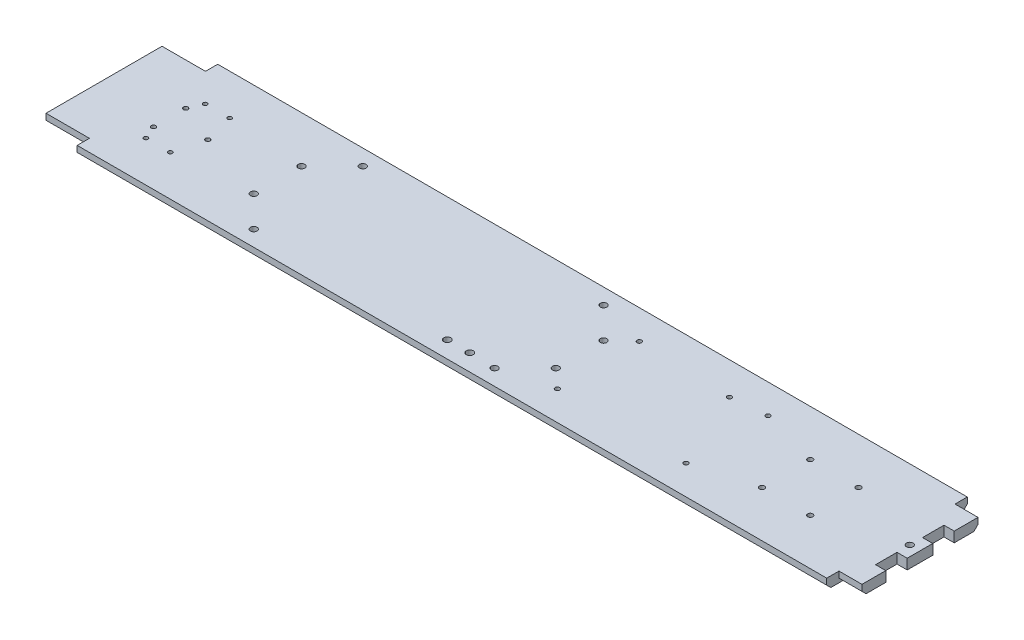
from build123d import *

# Parameters (mm, degrees)
SKETCH1_W           = 520
SKETCH1_H           = 87.376
BOSS_EXTRUDE1_DEPTH = 6.35
SKETCH3_W           = 27
SKETCH3_H           = 7.62
CUT_EXTRUDE2_DEPTH  = 7.35
SKETCH6_W           = 12.7
SKETCH6_H           = 72.136
CUT_EXTRUDE5_DEPTH  = 7.35
SKETCH8_R           = 1.4
CUT_EXTRUDE7_DEPTH  = 7.35
SKETCH9_R           = 2.05
CUT_EXTRUDE8_DEPTH  = 7.35
CHAMFER1_SIZE       = 2.54
SKETCH10_R          = 1.4
CUT_EXTRUDE9_DEPTH  = 7.35
SKETCH11_R          = 2.05
CUT_EXTRUDE10_DEPTH = 7.35
SKETCH12_R          = 1.27
CUT_EXTRUDE11_DEPTH = 7.35
SKETCH13_W          = 6.35
SKETCH13_H          = 13.335
CUT_EXTRUDE12_DEPTH = 7.35
SKETCH14_R          = 1.6
CUT_EXTRUDE13_DEPTH = 7.35
SKETCH15_R          = 2.15
CUT_EXTRUDE14_DEPTH = 7.35


with BuildPart() as part:
    # Sketch1 → Boss-Extrude1 (new body)
    with BuildSketch(Plane(origin=(0, 0, 0), x_dir=(1, 0, 0), z_dir=(0, 1, 0))):
        Rectangle(SKETCH1_W, SKETCH1_H)
    extrude(amount=BOSS_EXTRUDE1_DEPTH)

    # Sketch3 → Cut-Extrude2 (cut, through all)
    with BuildSketch(Plane(origin=(0, 6.35, 0), x_dir=(1, 0, 0), z_dir=(0, 1, 0))):
        with Locations((-246.5, 39.878)):
            Rectangle(SKETCH3_W, SKETCH3_H)
        with Locations((-246.5, -39.878)):
            Rectangle(SKETCH3_W, SKETCH3_H)
        with Locations((246.5, -39.878)):
            Rectangle(SKETCH3_W, SKETCH3_H)
        with Locations((246.5, 39.878)):
            Rectangle(SKETCH3_W, SKETCH3_H)
    extrude(amount=-CUT_EXTRUDE2_DEPTH, mode=Mode.SUBTRACT)

    # Sketch6 → Cut-Extrude5 (cut, through all)
    with BuildSketch(Plane(origin=(0, 6.35, 0), x_dir=(1, 0, 0), z_dir=(0, 1, 0))):
        with Locations((253.65, 0)):
            Rectangle(SKETCH6_W, SKETCH6_H)
    extrude(amount=-CUT_EXTRUDE5_DEPTH, mode=Mode.SUBTRACT)

    # Sketch8 → Cut-Extrude7 (cut, through all)
    with BuildSketch(Plane(origin=(0, 6.35, 0), x_dir=(1, 0, 0), z_dir=(0, 1, 0))):
        with Locations((-219.2, 10)):
            Circle(SKETCH8_R)
        with Locations((-219.2, -10)):
            Circle(SKETCH8_R)
        with Locations((-195.5, 0)):
            Circle(SKETCH8_R)
    extrude(amount=-CUT_EXTRUDE7_DEPTH, mode=Mode.SUBTRACT)

    # Sketch9 → Cut-Extrude8 (cut, through all)
    with BuildSketch(Plane(origin=(0, 6.35, 0), x_dir=(1, 0, 0), z_dir=(0, 1, 0))):
        with Locations((-133, 33.89)):
            Circle(SKETCH9_R)
        with Locations((-152.05, 14.84)):
            Circle(SKETCH9_R)
        with Locations((-152.05, -14.84)):
            Circle(SKETCH9_R)
        with Locations((-133, -33.89)):
            Circle(SKETCH9_R)
        with Locations((16.68, 33.89)):
            Circle(SKETCH9_R)
        with Locations((35.73, 14.84)):
            Circle(SKETCH9_R)
        with Locations((35.73, -14.84)):
            Circle(SKETCH9_R)
        with Locations((16.68, -33.89)):
            Circle(SKETCH9_R)
    extrude(amount=-CUT_EXTRUDE8_DEPTH, mode=Mode.SUBTRACT)

    # Chamfer1
    chamfer1_edges = [part.edges().sort_by_distance(p)[0] for p in [
        (0, 0, -43.688),
        (0, 0, 43.688),
        (240.15, 0, -36.068),
        (-246.5, 0, 36.068),
        (-246.5, 0, -36.068),
        (240.15, 0, 36.068),
    ]]
    chamfer(chamfer1_edges, length=CHAMFER1_SIZE)

    # Sketch10 → Cut-Extrude9 (cut, through all)
    with BuildSketch(Plane(origin=(0, 6.35, 0), x_dir=(1, 0, 0), z_dir=(0, 1, 0))):
        with Locations((47.34, 25.5)):
            Circle(SKETCH10_R)
        with Locations((127.34000002, 25.5)):
            Circle(SKETCH10_R)
        with Locations((47.34, -25.5)):
            Circle(SKETCH10_R)
        with Locations((127.34000002, -25.5)):
            Circle(SKETCH10_R)
        with Locations((105.34, 23.5)):
            Circle(SKETCH10_R)
    extrude(amount=-CUT_EXTRUDE9_DEPTH, mode=Mode.SUBTRACT)

    # Sketch11 → Cut-Extrude10 (cut, through all)
    with BuildSketch(Plane(origin=(0, 6.35, 0), x_dir=(1, 0, 0), z_dir=(0, 1, 0))):
        with Locations((240.95, 0)):
            Circle(SKETCH11_R)
    extrude(amount=-CUT_EXTRUDE10_DEPTH, mode=Mode.SUBTRACT)

    # Sketch12 → Cut-Extrude11 (cut, through all)
    with BuildSketch(Plane(origin=(0, 6.35, 0), x_dir=(1, 0, 0), z_dir=(0, 1, 0))):
        with Locations((-215.55, -18.415)):
            Circle(SKETCH12_R)
        with Locations((-215.55, 18.415)):
            Circle(SKETCH12_R)
        with Locations((-200.31, 18.415)):
            Circle(SKETCH12_R)
        with Locations((-200.31, -18.415)):
            Circle(SKETCH12_R)
    extrude(amount=-CUT_EXTRUDE11_DEPTH, mode=Mode.SUBTRACT)

    # Sketch13 → Cut-Extrude12 (cut, through all)
    with BuildSketch(Plane(origin=(0, 6.35, 0), x_dir=(1, 0, 0), z_dir=(0, 1, 0))):
        with Locations((244.125, -14.605)):
            Rectangle(SKETCH13_W, SKETCH13_H)
        with Locations((244.125, 14.605)):
            Rectangle(SKETCH13_W, SKETCH13_H)
    extrude(amount=-CUT_EXTRUDE12_DEPTH, mode=Mode.SUBTRACT)

    # Sketch14 → Cut-Extrude13 (cut, through all)
    with BuildSketch(Plane(origin=(0, 6.35, 0), x_dir=(1, 0, 0), z_dir=(0, 1, 0))):
        with Locations((164.053, -15)):
            Circle(SKETCH14_R)
        with Locations((194.053, -15)):
            Circle(SKETCH14_R)
        with Locations((164.053, 15)):
            Circle(SKETCH14_R)
        with Locations((194.053, 15)):
            Circle(SKETCH14_R)
    extrude(amount=-CUT_EXTRUDE13_DEPTH, mode=Mode.SUBTRACT)

    # Sketch15 → Cut-Extrude14 (cut, through all)
    with BuildSketch(Plane(origin=(0, 6.35, 0), x_dir=(1, 0, 0), z_dir=(0, 1, 0))):
        with Locations((0.68, -33.274)):
            Circle(SKETCH15_R)
        with Locations((-13.32, -33.274)):
            Circle(SKETCH15_R)
    extrude(amount=-CUT_EXTRUDE14_DEPTH, mode=Mode.SUBTRACT)


solid = part.part
